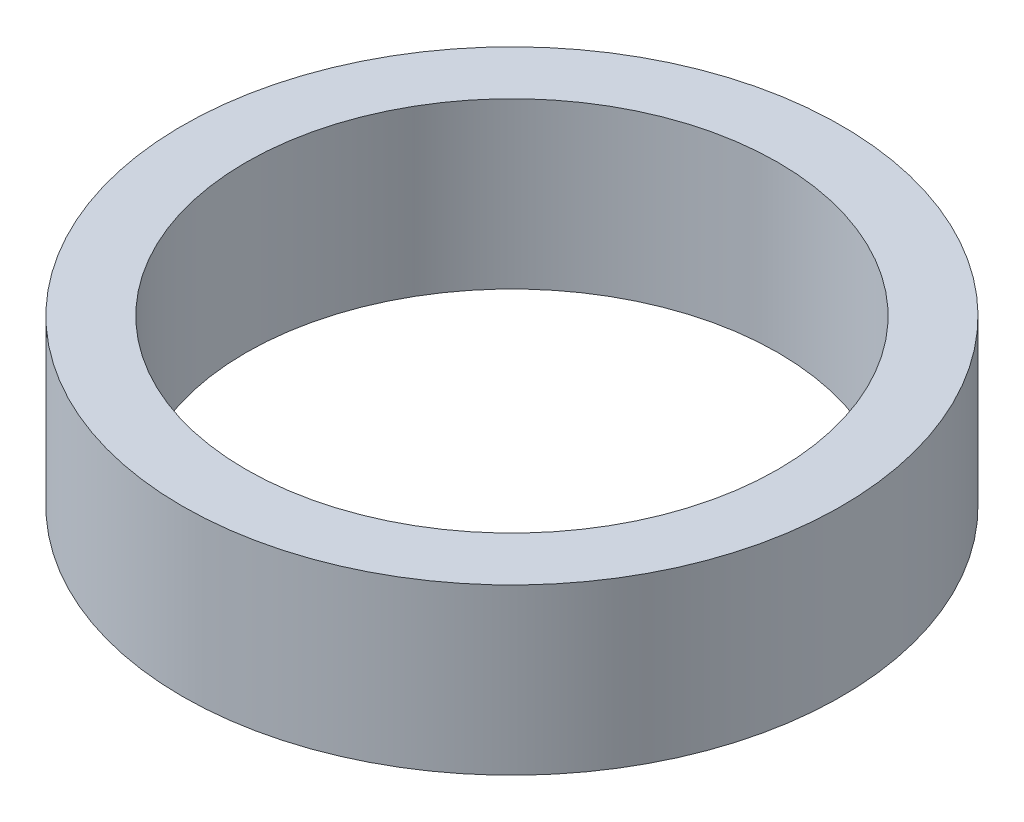
from build123d import *

# Parameters (mm, degrees)
SKETCH_1_W = 4.9
SKETCH_1_H = 12.7


with BuildPart() as part:
    # 草图1 → 旋转1 (revolve)
    with BuildSketch(Plane.XY, mode=Mode.PRIVATE) as revolve_1_sk:
        with Locations((22.95, 6.35)):
            Rectangle(SKETCH_1_W, SKETCH_1_H)
    revolve(revolve_1_sk.sketch.rotate(Axis((0, 161.376166943, 0), (0, -1, 0)), 90), axis=Axis((0, 161.376166943, 0), (0, -1, 0)))  # turned: the seam where the file's is


solid = part.part
